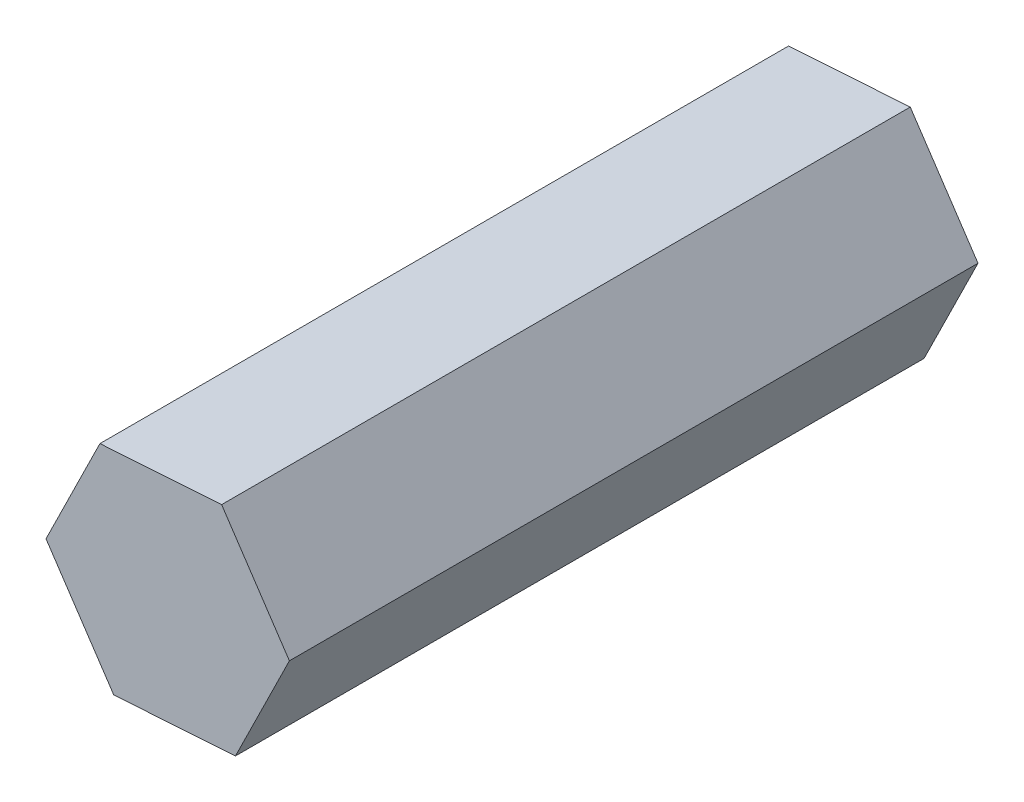
from build123d import *

# Parameters (mm, degrees)
BOSS_EXTRUDE1_DEPTH = 41.402


with BuildPart() as part:
    # Sketch1 → Boss-Extrude1 (new body)
    with BuildSketch(Plane.XY):
        Polygon((3.242368481, 6.576502107), (-4.074233653, 6.096224526), (-7.316602133, -0.480277581), (-3.242368481, -6.576502107), (4.074233653, -6.096224526), (7.316602133, 0.480277581), align=None)
    extrude(amount=BOSS_EXTRUDE1_DEPTH)


solid = part.part
